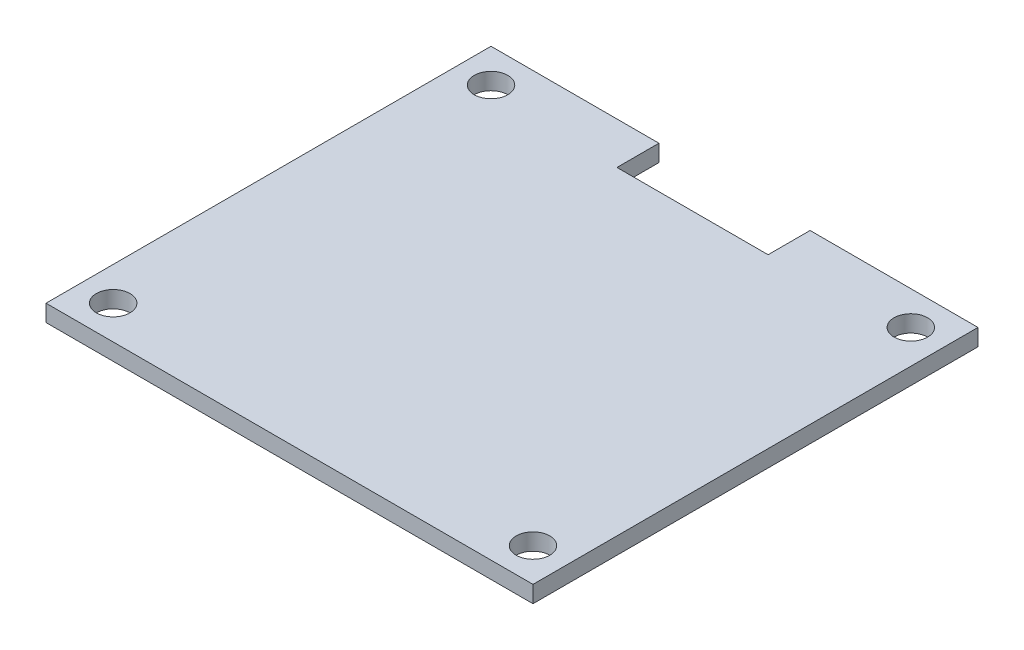
from build123d import *

# Parameters (mm, degrees)
SKETCH1_W                 = 58
SKETCH1_H                 = 53
BOSS_EXTRUDE1_DEPTH       = 2
F_4_0MM_DOWEL_HOLE1_D     = 4
F_4_0MM_DOWEL_HOLE1_DEPTH = 2
SKETCH4_W                 = 18
SKETCH4_H                 = 5
CUT_EXTRUDE1_DEPTH        = 2


with BuildPart() as part:
    # Sketch1 → Boss-Extrude1 (new body)
    with BuildSketch(Plane(origin=(0, 0, 0), x_dir=(1, 0, 0), z_dir=(0, 1, 0))):
        Rectangle(SKETCH1_W, SKETCH1_H)
    extrude(amount=BOSS_EXTRUDE1_DEPTH)

    # Ø4.0mm Dowel Hole1
    with Locations(Plane(origin=(0, 2, 0), x_dir=(1, 0, 0), z_dir=(0, 1, 0))):
        with Locations((25, 22.5), (-25, 22.5), (-25, -22.5), (25, -22.5)):
            Hole(F_4_0MM_DOWEL_HOLE1_D / 2, depth=F_4_0MM_DOWEL_HOLE1_DEPTH)

    # Sketch4 → Cut-Extrude1 (cut)
    with BuildSketch(Plane(origin=(0, 2, 0), x_dir=(1, 0, 0), z_dir=(0, 1, 0))):
        with Locations((0, 24)):
            Rectangle(SKETCH4_W, SKETCH4_H)
    extrude(amount=-CUT_EXTRUDE1_DEPTH, mode=Mode.SUBTRACT)


solid = part.part
